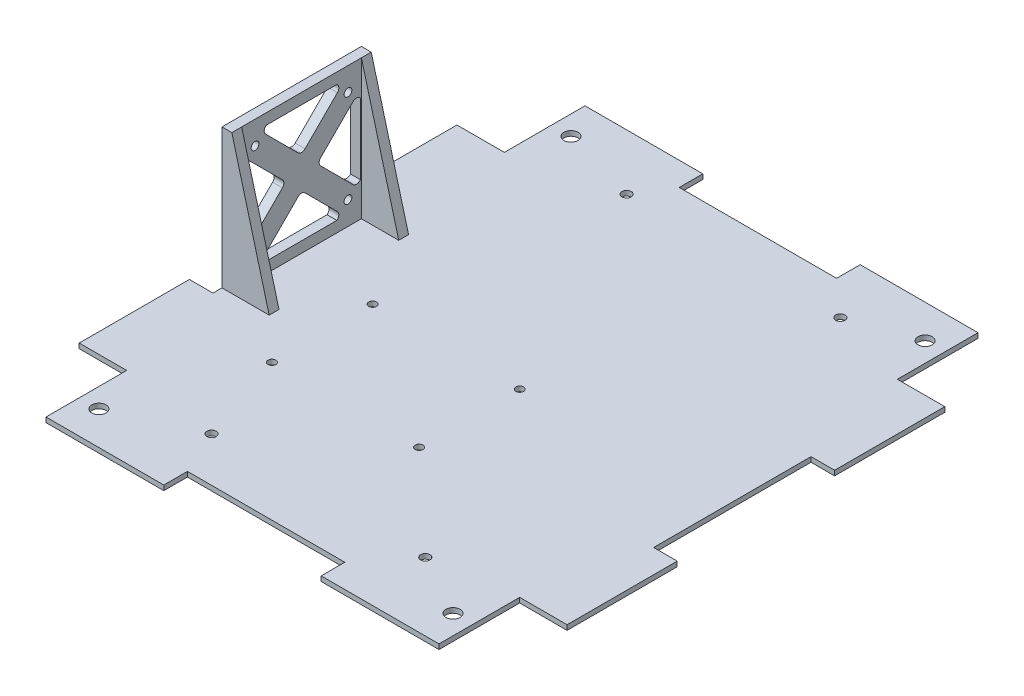
from build123d import *

# Parameters (mm, degrees)
SKETCH1_R           = 2.286
MAIN_BODY_DEPTH     = 1.5875
SKETCH8_W           = 3.175
SKETCH8_H           = 45
BOSS_EXTRUDE4_DEPTH = 45
BOSS_EXTRUDE5_DEPTH = 3.175
CUT_EXTRUDE2_REACH  = 151.86
SKETCH9_R           = 1.25
CUT_EXTRUDE3_REACH  = 48.587
SKETCH12_R          = 1.5
SKETCH12_R_2        = 1.25


with BuildPart() as part:
    # Sketch1 → Main Body (new body)
    with BuildSketch(Plane(origin=(0, 0, 0), x_dir=(1, 0, 0), z_dir=(0, 1, 0))):
        Polygon((-25.4, 86.995), (-63.43142, 86.995), (-63.43142, 60.96), (-78.74, 60.96), (-78.74, 25.4), (-71.12, 25.4), (-71.12, -25.4), (-78.74, -25.4), (-78.74, -60.96), (-63.43142, -60.96), (-63.43142, -86.995), (-25.4, -86.995), (-25.4, -79.375), (25.4, -79.375), (25.4, -86.995), (63.43142, -86.995), (63.43142, -60.96), (78.74, -60.96), (78.74, -25.4), (71.12, -25.4), (71.12, 25.4), (78.74, 25.4), (78.74, 60.96), (63.43142, 60.96), (63.43142, 86.995), (25.4, 86.995), (25.4, 79.375), (-25.4, 79.375), align=None)
        with Locations((-57.15, 76.2)):
            Circle(SKETCH1_R, mode=Mode.SUBTRACT)
        with Locations((57.15, 76.2)):
            Circle(SKETCH1_R, mode=Mode.SUBTRACT)
        with Locations((57.15, -76.2)):
            Circle(SKETCH1_R, mode=Mode.SUBTRACT)
        with Locations((-57.15, -76.2)):
            Circle(SKETCH1_R, mode=Mode.SUBTRACT)
    extrude(amount=MAIN_BODY_DEPTH)

    # Sketch8 → Boss-Extrude4 (add)
    with BuildSketch(Plane(origin=(0, 1.5875, 0), x_dir=(1, 0, 0), z_dir=(0, 1, 0))):
        with Locations((-69.5325, 0)):
            Rectangle(SKETCH8_W, SKETCH8_H)
    extrude(amount=BOSS_EXTRUDE4_DEPTH)

    # Sketch10 → Boss-Extrude5 (add)
    with BuildSketch(Plane.XY.offset(22.5)):
        Polygon((-67.945, 46.5875), (-67.945, 1.5875), (-55.887286341, 1.5875), align=None)
    boss_extrude5 = extrude(amount=-BOSS_EXTRUDE5_DEPTH)

    # Mirror3: Boss-Extrude5 across plane
    add(boss_extrude5.mirror(Plane.XY))

    # Sketch9 → Cut-Extrude2 (cut, up to next)
    with BuildSketch(Plane.ZY.offset(71.12), mode=Mode.PRIVATE) as cut_extrude2_sk1:
        with BuildLine():
            Line((-19, 35.504854797), (-19, 12.670145203))
            ThreePointArc((-19, 12.670145203), (-17.84383352, 12.048629236), (-16.614967985, 12.510032015))
            Line((-16.614967985, 12.510032015), (-6.160032015, 22.964967985))
            ThreePointArc((-6.160032015, 22.964967985), (-5.69506403, 24.0875), (-6.160032015, 25.210032015))
            Line((-6.160032015, 25.210032015), (-16.614967985, 35.664967985))
            ThreePointArc((-16.614967985, 35.664967985), (-17.84383352, 36.126370764), (-19, 35.504854797))
        make_face()
    cut_extrude2_tool1 = extrude(cut_extrude2_sk1.sketch, amount=-CUT_EXTRUDE2_REACH, mode=Mode.PRIVATE) & part.part
    add(cut_extrude2_tool1.solids().sort_by_distance((-71.12, 24.0875, -14.28057))[0], mode=Mode.SUBTRACT)
    # Sketch9 → Cut-Extrude2 (cut, up to next)
    with BuildSketch(Plane.ZY.offset(71.12), mode=Mode.PRIVATE) as cut_extrude2_sk2:
        with BuildLine():
            ThreePointArc((16.614967985, 12.510032015), (17.84383352, 12.048629236), (19, 12.670145203))
            Line((19, 12.670145203), (19, 35.504854797))
            ThreePointArc((19, 35.504854797), (17.84383352, 36.126370764), (16.614967985, 35.664967985))
            Line((16.614967985, 35.664967985), (6.160032015, 25.210032015))
            ThreePointArc((6.160032015, 25.210032015), (5.69506403, 24.0875), (6.160032015, 22.964967985))
            Line((6.160032015, 22.964967985), (16.614967985, 12.510032015))
        make_face()
    cut_extrude2_tool2 = extrude(cut_extrude2_sk2.sketch, amount=-CUT_EXTRUDE2_REACH, mode=Mode.PRIVATE) & part.part
    add(cut_extrude2_tool2.solids().sort_by_distance((-71.12, 24.0875, 14.28057))[0], mode=Mode.SUBTRACT)
    # Sketch9 → Cut-Extrude2 (cut, up to next)
    with BuildSketch(Plane.ZY.offset(71.12), mode=Mode.PRIVATE) as cut_extrude2_sk3:
        with BuildLine():
            ThreePointArc((-11.577467985, 7.472532015), (-12.038870764, 6.24366648), (-11.417354797, 5.0875))
            Line((-11.417354797, 5.0875), (11.417354797, 5.0875))
            ThreePointArc((11.417354797, 5.0875), (12.038870764, 6.24366648), (11.577467985, 7.472532015))
            Line((11.577467985, 7.472532015), (1.122532015, 17.927467985))
            ThreePointArc((1.122532015, 17.927467985), (0, 18.39243597), (-1.122532015, 17.927467985))
            Line((-1.122532015, 17.927467985), (-11.577467985, 7.472532015))
        make_face()
    cut_extrude2_tool3 = extrude(cut_extrude2_sk3.sketch, amount=-CUT_EXTRUDE2_REACH, mode=Mode.PRIVATE) & part.part
    add(cut_extrude2_tool3.solids().sort_by_distance((-71.12, 9.80693, 0))[0], mode=Mode.SUBTRACT)
    # Sketch9 → Cut-Extrude2 (cut, up to next)
    with BuildSketch(Plane.ZY.offset(71.12), mode=Mode.PRIVATE) as cut_extrude2_sk4:
        with BuildLine():
            Line((11.417354797, 43.0875), (-11.417354797, 43.0875))
            ThreePointArc((-11.417354797, 43.0875), (-12.038870764, 41.93133352), (-11.577467985, 40.702467985))
            Line((-11.577467985, 40.702467985), (-1.122532015, 30.247532015))
            ThreePointArc((-1.122532015, 30.247532015), (0, 29.78256403), (1.122532015, 30.247532015))
            Line((1.122532015, 30.247532015), (11.577467985, 40.702467985))
            ThreePointArc((11.577467985, 40.702467985), (12.038870764, 41.93133352), (11.417354797, 43.0875))
        make_face()
    cut_extrude2_tool4 = extrude(cut_extrude2_sk4.sketch, amount=-CUT_EXTRUDE2_REACH, mode=Mode.PRIVATE) & part.part
    add(cut_extrude2_tool4.solids().sort_by_distance((-71.12, 38.36807, 0))[0], mode=Mode.SUBTRACT)
    # Sketch9 → Cut-Extrude2 (cut, up to next)
    with BuildSketch(Plane.ZY.offset(71.12), mode=Mode.PRIVATE) as cut_extrude2_sk5:
        with Locations((15, 39.087508)):
            Circle(SKETCH9_R)
    cut_extrude2_tool5 = extrude(cut_extrude2_sk5.sketch, amount=-CUT_EXTRUDE2_REACH, mode=Mode.PRIVATE) & part.part
    add(cut_extrude2_tool5.solids().sort_by_distance((-71.12, 39.087508, 15))[0], mode=Mode.SUBTRACT)
    # Sketch9 → Cut-Extrude2 (cut, up to next)
    with BuildSketch(Plane.ZY.offset(71.12), mode=Mode.PRIVATE) as cut_extrude2_sk6:
        with Locations((-15, 39.087508)):
            Circle(SKETCH9_R)
    cut_extrude2_tool6 = extrude(cut_extrude2_sk6.sketch, amount=-CUT_EXTRUDE2_REACH, mode=Mode.PRIVATE) & part.part
    add(cut_extrude2_tool6.solids().sort_by_distance((-71.12, 39.087508, -15))[0], mode=Mode.SUBTRACT)
    # Sketch9 → Cut-Extrude2 (cut, up to next)
    with BuildSketch(Plane.ZY.offset(71.12), mode=Mode.PRIVATE) as cut_extrude2_sk7:
        with Locations((-15, 9.0875)):
            Circle(SKETCH9_R)
    cut_extrude2_tool7 = extrude(cut_extrude2_sk7.sketch, amount=-CUT_EXTRUDE2_REACH, mode=Mode.PRIVATE) & part.part
    add(cut_extrude2_tool7.solids().sort_by_distance((-71.12, 9.0875, -15))[0], mode=Mode.SUBTRACT)
    # Sketch9 → Cut-Extrude2 (cut, up to next)
    with BuildSketch(Plane.ZY.offset(71.12), mode=Mode.PRIVATE) as cut_extrude2_sk8:
        with Locations((15, 9.0875)):
            Circle(SKETCH9_R)
    cut_extrude2_tool8 = extrude(cut_extrude2_sk8.sketch, amount=-CUT_EXTRUDE2_REACH, mode=Mode.PRIVATE) & part.part
    add(cut_extrude2_tool8.solids().sort_by_distance((-71.12, 9.0875, 15))[0], mode=Mode.SUBTRACT)

    # Sketch12 → Cut-Extrude3 (cut, up to next)
    with BuildSketch(Plane.XZ, mode=Mode.PRIVATE) as cut_extrude3_sk1:
        with Locations((-32, -69)):
            Circle(SKETCH12_R)
    cut_extrude3_tool1 = extrude(cut_extrude3_sk1.sketch, amount=-CUT_EXTRUDE3_REACH, mode=Mode.PRIVATE) & part.part
    add(cut_extrude3_tool1.solids().sort_by_distance((-32, 0, -69))[0], mode=Mode.SUBTRACT)
    # Sketch12 → Cut-Extrude3 (cut, up to next)
    with BuildSketch(Plane.XZ, mode=Mode.PRIVATE) as cut_extrude3_sk2:
        with Locations((37, -69)):
            Circle(SKETCH12_R)
    cut_extrude3_tool2 = extrude(cut_extrude3_sk2.sketch, amount=-CUT_EXTRUDE3_REACH, mode=Mode.PRIVATE) & part.part
    add(cut_extrude3_tool2.solids().sort_by_distance((37, 0, -69))[0], mode=Mode.SUBTRACT)
    # Sketch12 → Cut-Extrude3 (cut, up to next)
    with BuildSketch(Plane.XZ, mode=Mode.PRIVATE) as cut_extrude3_sk3:
        with Locations((37, 65)):
            Circle(SKETCH12_R)
    cut_extrude3_tool3 = extrude(cut_extrude3_sk3.sketch, amount=-CUT_EXTRUDE3_REACH, mode=Mode.PRIVATE) & part.part
    add(cut_extrude3_tool3.solids().sort_by_distance((37, 0, 65))[0], mode=Mode.SUBTRACT)
    # Sketch12 → Cut-Extrude3 (cut, up to next)
    with BuildSketch(Plane.XZ, mode=Mode.PRIVATE) as cut_extrude3_sk4:
        with Locations((-32, 65)):
            Circle(SKETCH12_R)
    cut_extrude3_tool4 = extrude(cut_extrude3_sk4.sketch, amount=-CUT_EXTRUDE3_REACH, mode=Mode.PRIVATE) & part.part
    add(cut_extrude3_tool4.solids().sort_by_distance((-32, 0, 65))[0], mode=Mode.SUBTRACT)
    # Sketch12 → Cut-Extrude3 (cut, up to next)
    with BuildSketch(Plane.XZ, mode=Mode.PRIVATE) as cut_extrude3_sk5:
        with Locations((-42.25, 2.75)):
            Circle(SKETCH12_R_2)
    cut_extrude3_tool5 = extrude(cut_extrude3_sk5.sketch, amount=-CUT_EXTRUDE3_REACH, mode=Mode.PRIVATE) & part.part
    add(cut_extrude3_tool5.solids().sort_by_distance((-42.25, 0, 2.75))[0], mode=Mode.SUBTRACT)
    # Sketch12 → Cut-Extrude3 (cut, up to next)
    with BuildSketch(Plane.XZ, mode=Mode.PRIVATE) as cut_extrude3_sk6:
        with Locations((-42.25, 35.25)):
            Circle(SKETCH12_R_2)
    cut_extrude3_tool6 = extrude(cut_extrude3_sk6.sketch, amount=-CUT_EXTRUDE3_REACH, mode=Mode.PRIVATE) & part.part
    add(cut_extrude3_tool6.solids().sort_by_distance((-42.25, 0, 35.25))[0], mode=Mode.SUBTRACT)
    # Sketch12 → Cut-Extrude3 (cut, up to next)
    with BuildSketch(Plane.XZ, mode=Mode.PRIVATE) as cut_extrude3_sk7:
        with Locations((5.25, 2.75)):
            Circle(SKETCH12_R_2)
    cut_extrude3_tool7 = extrude(cut_extrude3_sk7.sketch, amount=-CUT_EXTRUDE3_REACH, mode=Mode.PRIVATE) & part.part
    add(cut_extrude3_tool7.solids().sort_by_distance((5.25, 0, 2.75))[0], mode=Mode.SUBTRACT)
    # Sketch12 → Cut-Extrude3 (cut, up to next)
    with BuildSketch(Plane.XZ, mode=Mode.PRIVATE) as cut_extrude3_sk8:
        with Locations((5.25, 35.25)):
            Circle(SKETCH12_R_2)
    cut_extrude3_tool8 = extrude(cut_extrude3_sk8.sketch, amount=-CUT_EXTRUDE3_REACH, mode=Mode.PRIVATE) & part.part
    add(cut_extrude3_tool8.solids().sort_by_distance((5.25, 0, 35.25))[0], mode=Mode.SUBTRACT)


solid = part.part
